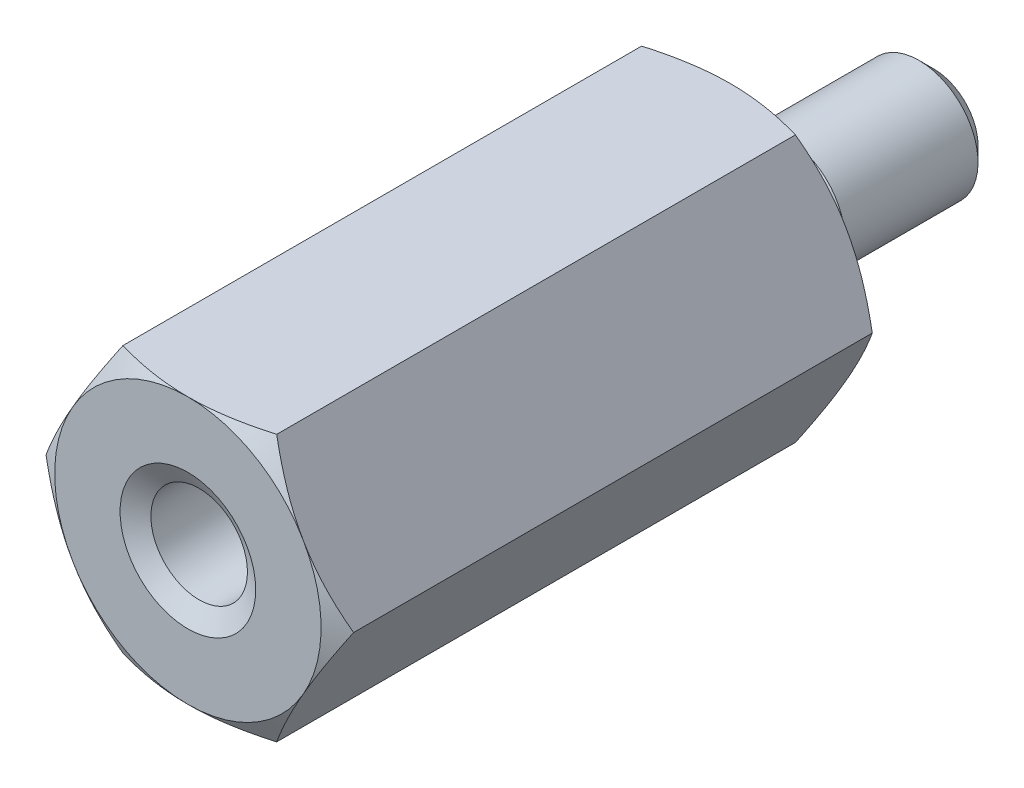
from build123d import *

# Parameters (mm, degrees)
EXTRUDE1_DEPTH                                 = 6.35
F_4_40_TAPPED_HOLE1_STANDARD_DEPTH_D           = 2.2606
F_4_40_TAPPED_HOLE1_STANDARD_DEPTH_DEPTH       = 8.255
F_4_40_TAPPED_HOLE1_STANDARD_DEPTH_CSINK_D     = 3.175
F_4_40_TAPPED_HOLE1_STANDARD_DEPTH_CSINK_ANGLE = 120
F_4_40_TAPPED_HOLE1_STANDARD_DEPTH_TIP         = 0.679152758


with BuildPart() as part:
    # Sketch1 → Extrude1 (new body, symmetric)
    with BuildSketch(Plane.XY):
        Polygon((3.600183074, 0), (1.800091537, 3.11785), (-1.800091537, 3.11785), (-3.600183074, 0), (-1.800091537, -3.11785), (1.800091537, -3.11785), align=None)
    extrude(amount=EXTRUDE1_DEPTH, both=True)

    # Sketch3 → Cut-Revolve1 (revolve, cut)
    with BuildSketch(Plane(origin=(0, 0, 0), x_dir=(0, 0, -1), z_dir=(1, 0, 0))):
        Polygon((-6.35, 3.11785), (-5.47011819, 4.64185), (-6.604, 4.64185), (-6.604, 3.11785), align=None)
    cut_revolve1 = revolve(axis=Axis((0, 0, 6.35), (0, 0, 1)), mode=Mode.SUBTRACT)

    # Mirror1: Cut-Revolve1 across plane
    add(cut_revolve1.mirror(Plane.XY), mode=Mode.SUBTRACT)

    # Sketch2 → 4-40 stud (revolve)
    with BuildSketch(Plane(origin=(0, 0, 0), x_dir=(0, 0, -1), z_dir=(1, 0, 0))):
        Polygon((6.35, 1.03378), (7.3025, 1.03378), (7.648575, 1.379855), (10.766425, 1.379855), (11.1125, 1.03378), (11.1125, 0), (6.35, 0), align=None)
    revolve(axis=Axis((0, 0, -6.35), (0, 0, 1)))

    # #4-40 Tapped Hole1 (STANDARD DEPTH)
    with Locations(Plane.XY.offset(6.35)):
        with Locations((0, 0)):
            CounterSinkHole(F_4_40_TAPPED_HOLE1_STANDARD_DEPTH_D / 2, F_4_40_TAPPED_HOLE1_STANDARD_DEPTH_CSINK_D / 2, depth=F_4_40_TAPPED_HOLE1_STANDARD_DEPTH_DEPTH, counter_sink_angle=F_4_40_TAPPED_HOLE1_STANDARD_DEPTH_CSINK_ANGLE)
            with Locations((0, 0, -(F_4_40_TAPPED_HOLE1_STANDARD_DEPTH_DEPTH + F_4_40_TAPPED_HOLE1_STANDARD_DEPTH_TIP / 2))):  # 118° drill point
                Cone(0, F_4_40_TAPPED_HOLE1_STANDARD_DEPTH_D / 2, F_4_40_TAPPED_HOLE1_STANDARD_DEPTH_TIP, mode=Mode.SUBTRACT)


solid = part.part
